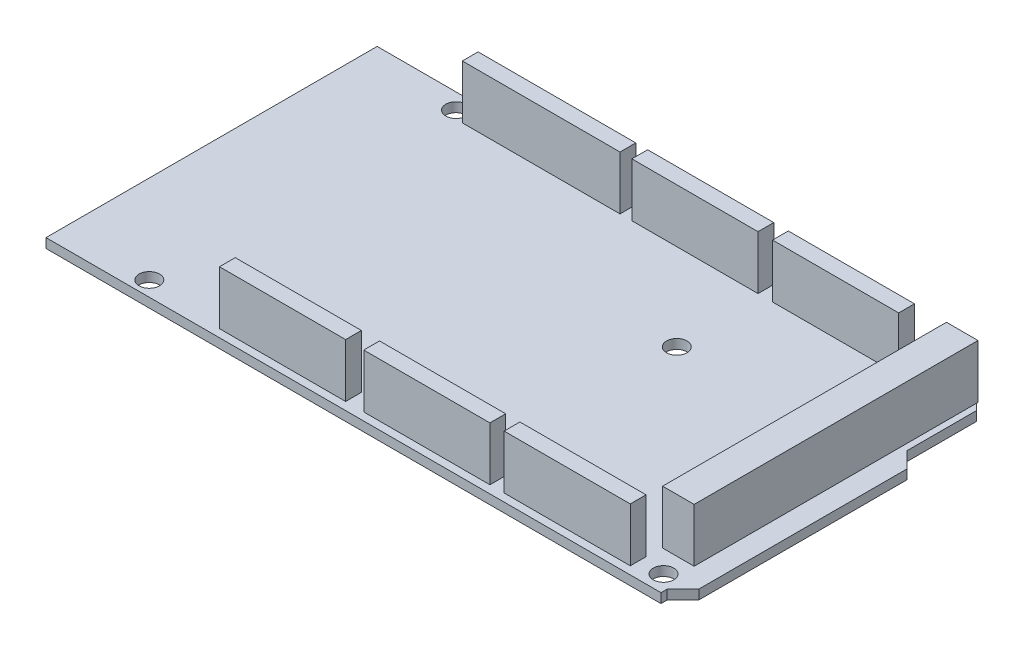
from build123d import *

# Parameters (mm, degrees)
BOSS_EXTRUDE1_DEPTH            = 0.762
F_1_3_1_3_DIAMETER_HOLE1_D     = 1.3
F_1_3_1_3_DIAMETER_HOLE1_DEPTH = 1.524
F_3_3_3_3_DIAMETER_HOLE1_D     = 3.3
F_3_3_3_3_DIAMETER_HOLE1_DEPTH = 1.524
SKETCH6_W                      = 25.4
SKETCH6_H                      = 2.54
BOSS_EXTRUDE2_DEPTH            = 8.636
SKETCH6_W_2                    = 20.32
BOSS_EXTRUDE2_2_DEPTH          = 8.636
BOSS_EXTRUDE2_3_DEPTH          = 8.636
SKETCH6_W_3                    = 5.08
SKETCH6_H_2                    = 45.72
BOSS_EXTRUDE2_4_DEPTH          = 8.636
BOSS_EXTRUDE2_5_DEPTH          = 8.636
BOSS_EXTRUDE2_6_DEPTH          = 8.636
BOSS_EXTRUDE2_7_DEPTH          = 8.636


with BuildPart() as part:
    # Sketch1 → Boss-Extrude1 (new body, symmetric)
    with BuildSketch(Plane(origin=(0, 0, 0), x_dir=(1, 0, 0), z_dir=(0, 1, 0))):
        Polygon((99.06, 39.608), (101.6, 37.068), (101.6, 3.54), (99.06, 1), (99.06, 0), (0, 0), (0, 53.34), (96.52, 53.34), (99.06, 50.8), align=None)
    extrude(amount=BOSS_EXTRUDE1_DEPTH, both=True)

    # Ø1.3 (1.3) Diameter Hole1
    with Locations(Plane(origin=(0, 0.762, 0), x_dir=(1, 0, 0), z_dir=(0, 1, 0))):
        with Locations((27.94, 2.54), (18.796, 50.8), (30.48, 2.54), (33.02, 2.54), (35.56, 2.54), (38.1, 2.54), (40.64, 2.54), (43.18, 2.54), (45.72, 2.54), (21.336, 50.8), (23.876, 50.8), (26.416, 50.8), (28.956, 50.8), (31.496, 50.8), (34.036, 50.8), (36.576, 50.8), (39.116, 50.8), (41.656, 50.8), (51.181, 2.54), (46.101, 50.8), (53.721, 2.54), (56.261, 2.54), (58.801, 2.54), (61.341, 2.54), (63.881, 2.54), (66.421, 2.54), (68.961, 2.54), (48.641, 50.8), (51.181, 50.8), (53.721, 50.8), (56.261, 50.8), (58.801, 50.8), (61.341, 50.8), (63.881, 50.8), (68.7578, 50.8), (73.787, 2.54), (71.2978, 50.8), (76.327, 2.54), (73.8378, 50.8), (78.867, 2.54), (76.3778, 50.8), (81.407, 2.54), (78.9178, 50.8), (83.947, 2.54), (81.4578, 50.8), (86.487, 2.54), (83.9978, 50.8), (89.027, 2.54), (86.5378, 50.8), (91.567, 2.54), (94.234, 50.8), (96.774, 50.8), (94.234, 48.26), (96.774, 48.26), (94.234, 45.72), (96.774, 45.72), (94.234, 43.18), (96.774, 43.18), (94.234, 40.64), (96.774, 40.64), (94.234, 38.1), (96.774, 38.1), (94.234, 35.56), (96.774, 35.56), (94.234, 33.02), (96.774, 33.02), (94.234, 30.48), (96.774, 30.48), (94.234, 27.94), (96.774, 27.94), (94.234, 25.4), (96.774, 25.4), (94.234, 22.86), (96.774, 22.86), (94.234, 20.32), (96.774, 20.32), (94.234, 17.78), (96.774, 17.78), (94.234, 15.24), (96.774, 15.24), (94.234, 12.7), (96.774, 12.7), (94.234, 10.16), (96.774, 10.16), (94.234, 7.62), (96.774, 7.62)):
            Hole(F_1_3_1_3_DIAMETER_HOLE1_D / 2, depth=F_1_3_1_3_DIAMETER_HOLE1_DEPTH)

    # Ø3.3 (3.3) Diameter Hole1
    with Locations(Plane(origin=(0, 0.762, 0), x_dir=(1, 0, 0), z_dir=(0, 1, 0))):
        with Locations((15.24, 50.8), (90.3732, 50.8), (96.647, 2.809446088), (66.04, 7.366), (66.04, 35.56), (14.224, 2.413)):
            Hole(F_3_3_3_3_DIAMETER_HOLE1_D / 2, depth=F_3_3_3_3_DIAMETER_HOLE1_DEPTH)


with BuildPart() as body_2:
    # Sketch6 → Boss-Extrude2 (new body)
    with BuildSketch(Plane(origin=(0, 0.762, 0), x_dir=(1, 0, 0), z_dir=(0, 1, 0))):
        with Locations((30.226, 50.8)):
            Rectangle(SKETCH6_W, SKETCH6_H)
    extrude(amount=BOSS_EXTRUDE2_DEPTH)


with BuildPart() as body_3:
    # Sketch6 → Boss-Extrude2 2 (new body)
    with BuildSketch(Plane(origin=(0, 0.762, 0), x_dir=(1, 0, 0), z_dir=(0, 1, 0))):
        with Locations((54.991, 50.8)):
            Rectangle(SKETCH6_W_2, SKETCH6_H)
    extrude(amount=BOSS_EXTRUDE2_2_DEPTH)


with BuildPart() as body_4:
    # Sketch6 → Boss-Extrude2 3 (new body)
    with BuildSketch(Plane(origin=(0, 0.762, 0), x_dir=(1, 0, 0), z_dir=(0, 1, 0))):
        with Locations((77.6478, 50.8)):
            Rectangle(SKETCH6_W_2, SKETCH6_H)
    extrude(amount=BOSS_EXTRUDE2_3_DEPTH)


with BuildPart() as body_5:
    # Sketch6 → Boss-Extrude2 4 (new body)
    with BuildSketch(Plane(origin=(0, 0.762, 0), x_dir=(1, 0, 0), z_dir=(0, 1, 0))):
        with Locations((95.504, 29.21)):
            Rectangle(SKETCH6_W_3, SKETCH6_H_2)
    extrude(amount=BOSS_EXTRUDE2_4_DEPTH)


with BuildPart() as body_6:
    # Sketch6 → Boss-Extrude2 5 (new body)
    with BuildSketch(Plane(origin=(0, 0.762, 0), x_dir=(1, 0, 0), z_dir=(0, 1, 0))):
        with Locations((82.677, 2.54)):
            Rectangle(SKETCH6_W_2, SKETCH6_H)
    extrude(amount=BOSS_EXTRUDE2_5_DEPTH)


with BuildPart() as body_7:
    # Sketch6 → Boss-Extrude2 6 (new body)
    with BuildSketch(Plane(origin=(0, 0.762, 0), x_dir=(1, 0, 0), z_dir=(0, 1, 0))):
        with Locations((36.83, 2.54)):
            Rectangle(SKETCH6_W_2, SKETCH6_H)
    extrude(amount=BOSS_EXTRUDE2_6_DEPTH)


with BuildPart() as body_8:
    # Sketch6 → Boss-Extrude2 7 (new body)
    with BuildSketch(Plane(origin=(0, 0.762, 0), x_dir=(1, 0, 0), z_dir=(0, 1, 0))):
        with Locations((60.071, 2.54)):
            Rectangle(SKETCH6_W_2, SKETCH6_H)
    extrude(amount=BOSS_EXTRUDE2_7_DEPTH)


solid = Compound([part.part, body_2.part, body_3.part, body_4.part, body_5.part, body_6.part, body_7.part, body_8.part])
